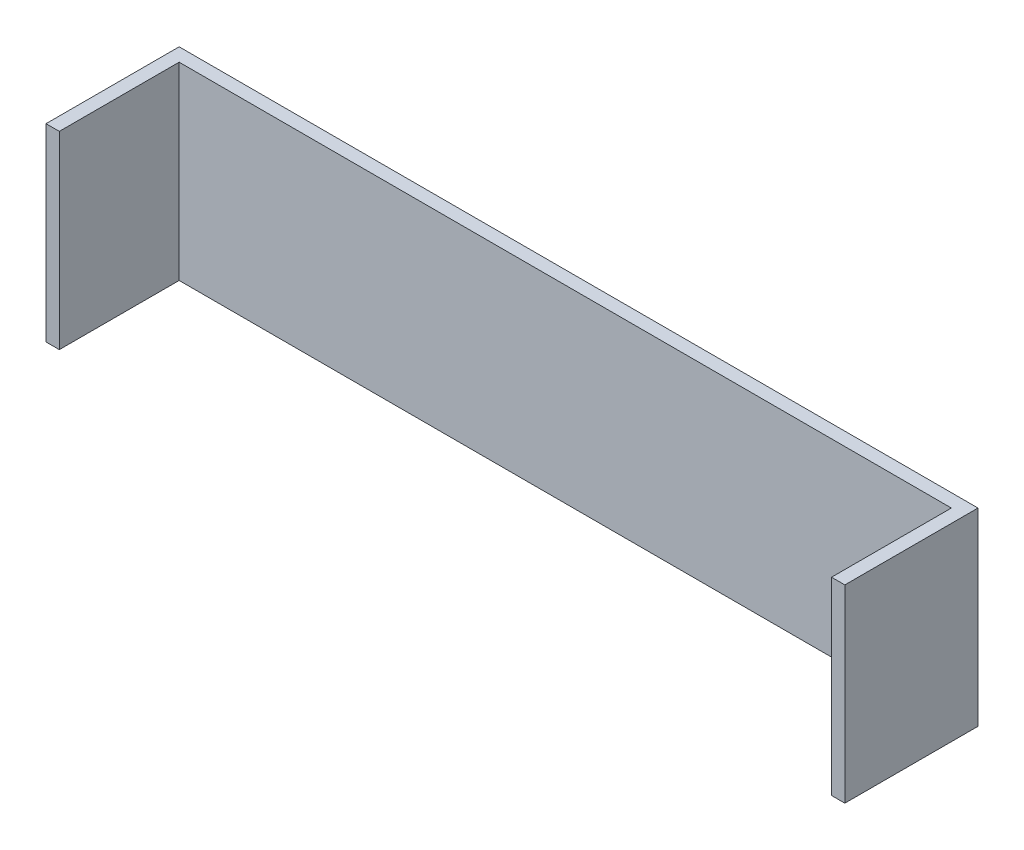
from build123d import *

# Parameters (mm, degrees)
EXTRUDE_THIN1_DEPTH = 45.085


with BuildPart() as part:
    # Sketch1 → Extrude-Thin1 (new body, symmetric)
    with BuildSketch(Plane(origin=(0, 0, 0), x_dir=(1, 0, 0), z_dir=(0, 1, 0))):
        Polygon((-190.5, -63.5), (-190.5, 0), (190.5, 0), (190.5, -63.5), (184.15, -63.5), (184.15, -6.35), (-184.15, -6.35), (-184.15, -63.5), align=None)
    extrude(amount=EXTRUDE_THIN1_DEPTH, both=True)


solid = part.part
